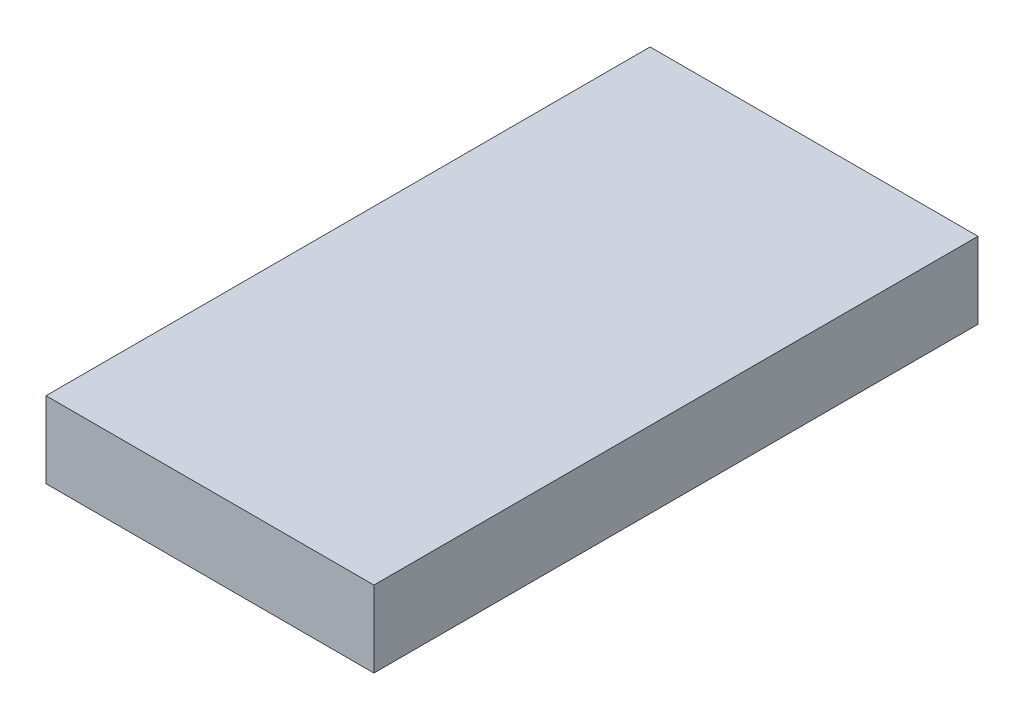
from build123d import *

# Parameters (mm, degrees)
SKETCH1_W           = 57
SKETCH1_H           = 105
BOSS_EXTRUDE1_DEPTH = 13.25


with BuildPart() as part:
    # Sketch1 → Boss-Extrude1 (new body)
    with BuildSketch(Plane(origin=(0, 0, 0), x_dir=(1, 0, 0), z_dir=(0, 1, 0))):
        Rectangle(SKETCH1_W, SKETCH1_H)
    extrude(amount=BOSS_EXTRUDE1_DEPTH)


solid = part.part
